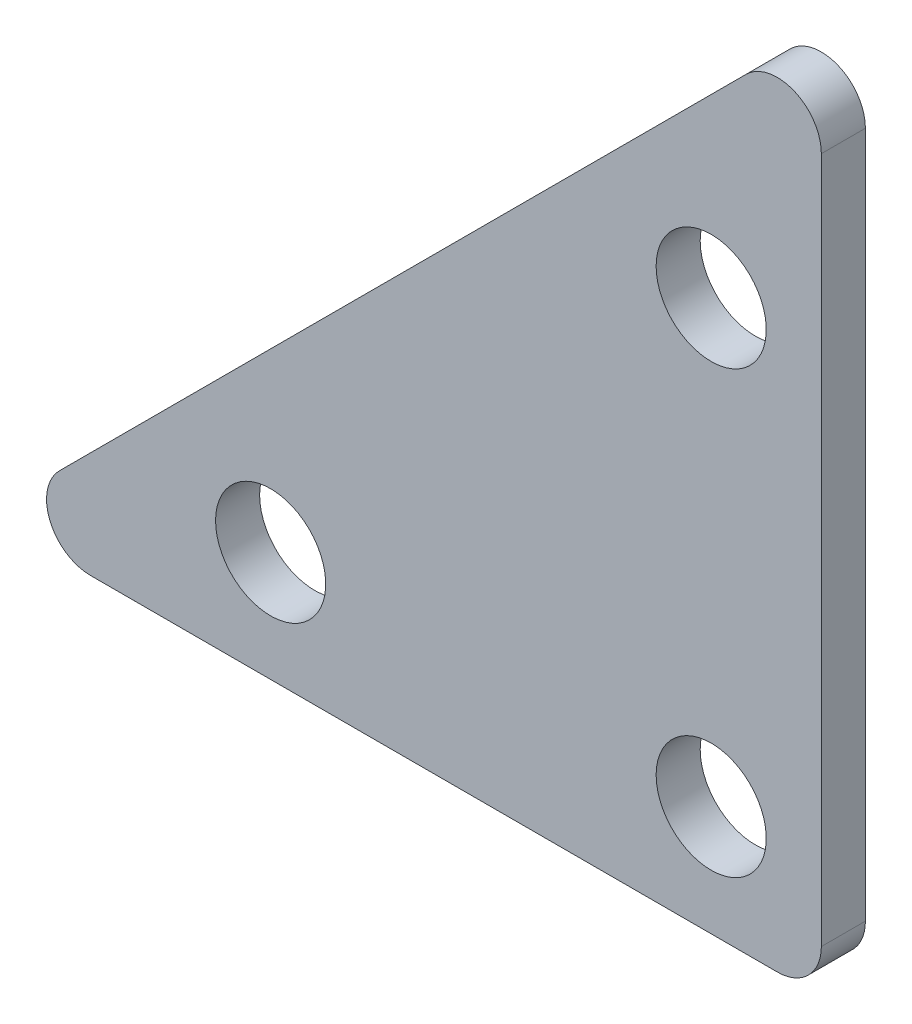
from build123d import *

# Parameters (mm, degrees)
BOSS_EXTRUDE1_DEPTH   = 2
F_5_0MM_DOWEL_HOLE1_D = 5
FILLET1_R             = 2


with BuildPart() as part:
    # Sketch1 → Boss-Extrude1 (new body)
    with BuildSketch(Plane.XY):
        Polygon((0, 0), (0, 38), (-38, 0), align=None)
    extrude(amount=BOSS_EXTRUDE1_DEPTH)

    # Ø5.0mm Dowel Hole1 (through all)
    with Locations(Plane(origin=(0, 0, 0), x_dir=(-1, 0, 0), z_dir=(0, 0, -1))):
        with Locations((5, 25), (5, 5), (25, 5)):
            Hole(F_5_0MM_DOWEL_HOLE1_D / 2)

    # Fillet1
    fillet1_edges = [part.edges().sort_by_distance(p)[0] for p in [
        (-38, 0, 1),
        (0, 38, 1),
        (0, 0, 1),
    ]]
    fillet(fillet1_edges, radius=FILLET1_R)


solid = part.part
